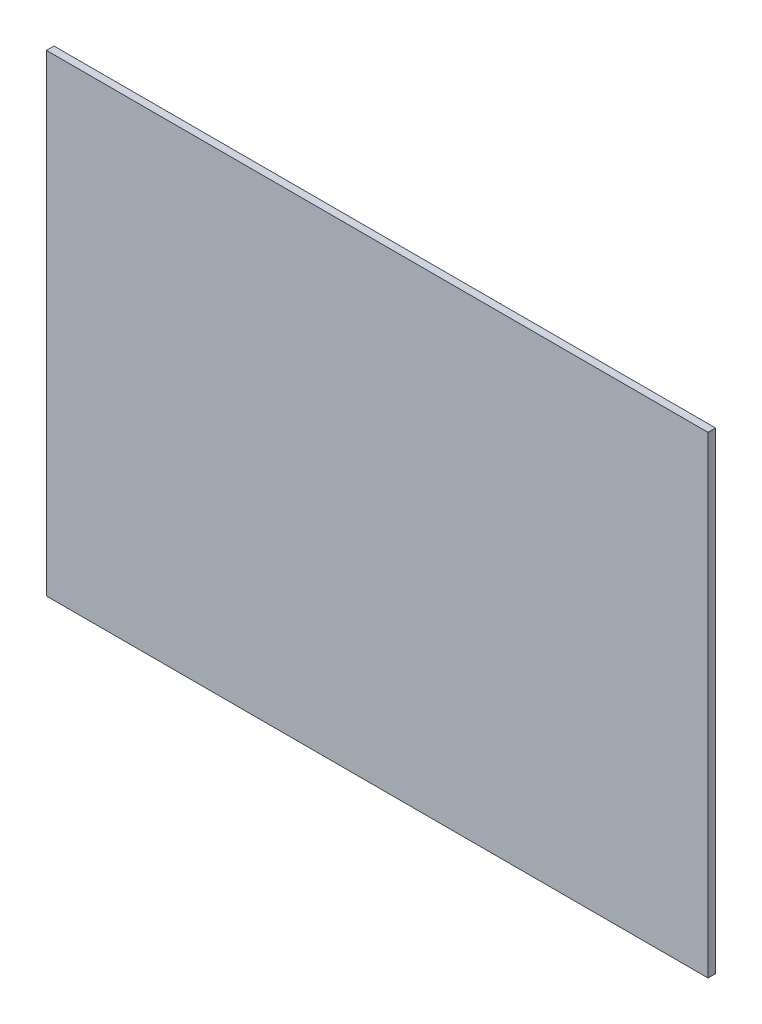
from build123d import *

# Parameters (mm, degrees)
SKETCH1_W           = 700
SKETCH1_H           = 500
BOSS_EXTRUDE1_DEPTH = 8


with BuildPart() as part:
    # Sketch1 → Boss-Extrude1 (new body)
    with BuildSketch(Plane.XY):
        with Locations((350, 250)):
            Rectangle(SKETCH1_W, SKETCH1_H)
    extrude(amount=BOSS_EXTRUDE1_DEPTH)


solid = part.part
